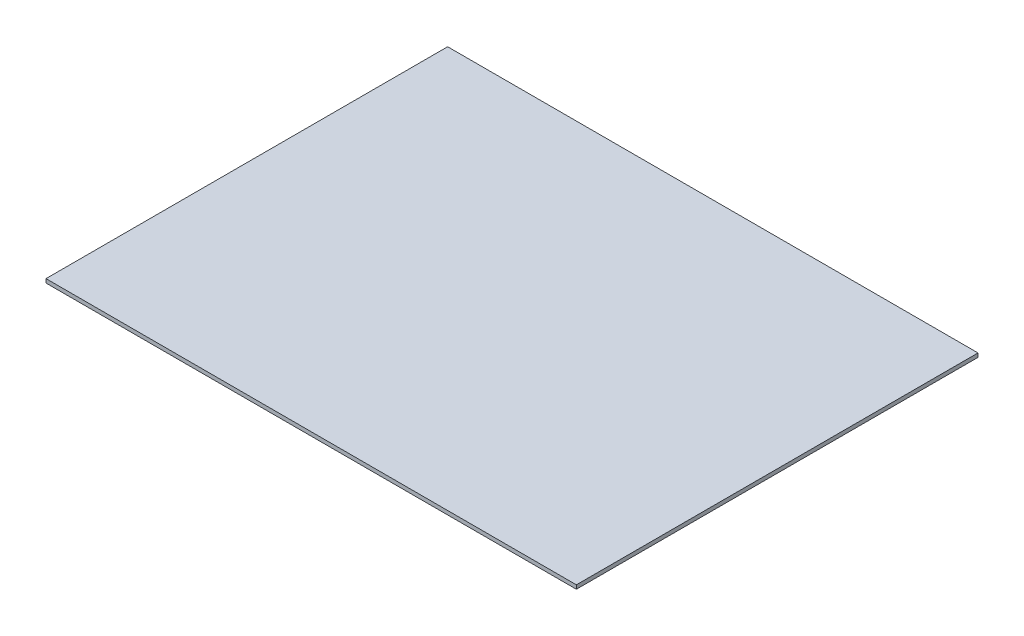
from build123d import *

# Parameters (mm, degrees)
SKETCH1_W           = 412
SKETCH1_H           = 312
BOSS_EXTRUDE1_DEPTH = 3


with BuildPart() as part:
    # Sketch1 → Boss-Extrude1 (new body)
    with BuildSketch(Plane(origin=(0, 0, 0), x_dir=(1, 0, 0), z_dir=(0, 1, 0))):
        with Locations((-19.932279394, 194.475033065)):
            Rectangle(SKETCH1_W, SKETCH1_H)
    extrude(amount=BOSS_EXTRUDE1_DEPTH)


solid = part.part
